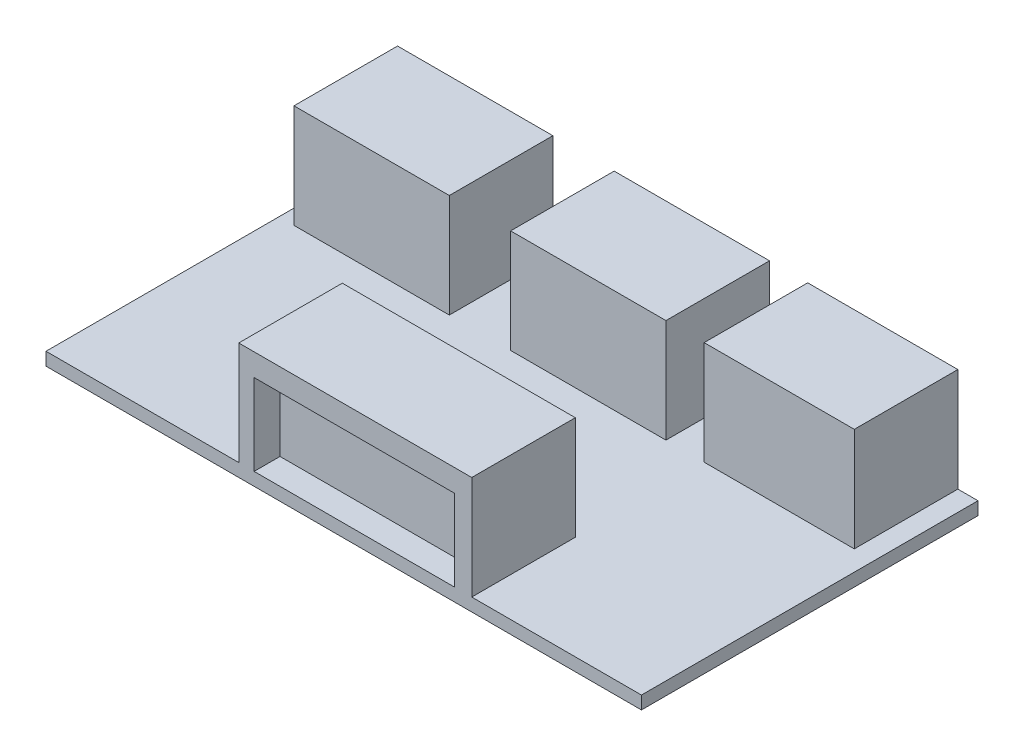
from build123d import *

# Parameters (mm, degrees)
SKETCH1_W           = 23
SKETCH1_H           = 13
BOSS_EXTRUDE1_DEPTH = 0.5
SKETCH2_W           = 5.8
SKETCH2_H           = 4
SKETCH2_W_2         = 6
SKETCH2_W_3         = 9
BOSS_EXTRUDE2_DEPTH = 4
SKETCH3_W           = 4.624085026
SKETCH3_H           = 3.166867164
SKETCH3_W_2         = 4.718514666
SKETCH3_H_2         = 3.013327786
SKETCH3_W_3         = 4.580400568
CUT_EXTRUDE1_DEPTH  = 1
SKETCH4_W           = 7.748769295
SKETCH4_H           = 3.140290714
CUT_EXTRUDE2_DEPTH  = 1


with BuildPart() as part:
    # Sketch1 → Boss-Extrude1 (new body)
    with BuildSketch(Plane(origin=(0, 0, 0), x_dir=(1, 0, 0), z_dir=(0, 1, 0))):
        with Locations((1.517204559, 1.070232191)):
            Rectangle(SKETCH1_W, SKETCH1_H)
    extrude(amount=BOSS_EXTRUDE1_DEPTH)

    # Sketch2 → Boss-Extrude2 (add)
    with BuildSketch(Plane(origin=(0, 0.5, 0), x_dir=(1, 0, 0), z_dir=(0, 1, 0))):
        with Locations((9.339285907, 5.570232191)):
            Rectangle(SKETCH2_W, SKETCH2_H)
        with Locations((-6.403857402, 5.570232191)):
            Rectangle(SKETCH2_W_2, SKETCH2_H)
        with Locations((1.963830733, 5.570232191)):
            Rectangle(SKETCH2_W_2, SKETCH2_H)
        with Locations((1.962518624, -3.429767809)):
            Rectangle(SKETCH2_W_3, SKETCH2_H)
    extrude(amount=BOSS_EXTRUDE2_DEPTH)

    # Sketch3 → Cut-Extrude1 (cut)
    with BuildSketch(Plane(origin=(0, 0, -7.570232191), x_dir=(-1, 0, 0), z_dir=(0, 0, -1))):
        with Locations((-9.393748211, 2.083433582)):
            Rectangle(SKETCH3_W, SKETCH3_H)
        with Locations((-1.920682759, 2.006663893)):
            Rectangle(SKETCH3_W_2, SKETCH3_H_2)
        with Locations((6.437297708, 2.006663893)):
            Rectangle(SKETCH3_W_3, SKETCH3_H_2)
    extrude(amount=-CUT_EXTRUDE1_DEPTH, mode=Mode.SUBTRACT)

    # Sketch4 → Cut-Extrude2 (cut)
    with BuildSketch(Plane.XY.offset(5.429767809)):
        with Locations((1.929978032, 2.070145357)):
            Rectangle(SKETCH4_W, SKETCH4_H)
    extrude(amount=-CUT_EXTRUDE2_DEPTH, mode=Mode.SUBTRACT)


solid = part.part
